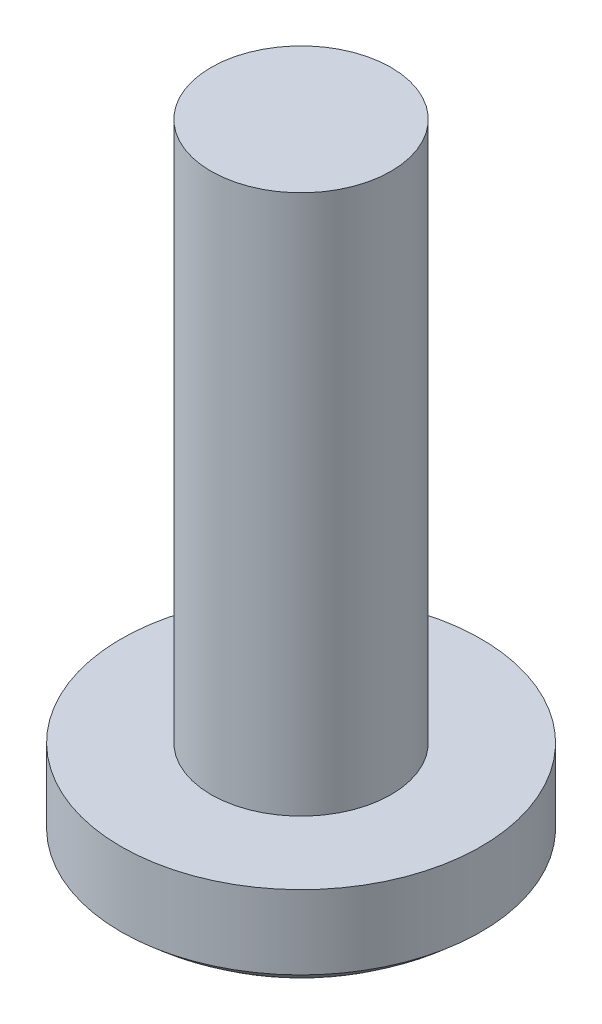
from build123d import *

# Parameters (mm, degrees)
SKETCH_1_R          = 2
EXTRUDE_1_DEPTH     = 1.6
SKETCH_2_R          = 1
EXTRUDE_2_DEPTH     = 6
CUT_EXTRUDE_1_DEPTH = 6


with BuildPart() as part:
    # 草图1 → 凸台-拉伸1 (new body)
    with BuildSketch(Plane(origin=(0, 0, 0), x_dir=(1, 0, 0), z_dir=(0, 1, 0))):
        Circle(SKETCH_1_R)
    extrude(amount=EXTRUDE_1_DEPTH)

    # 草图2 → 凸台-拉伸2 (add)
    with BuildSketch(Plane(origin=(0, 1.6, 0), x_dir=(1, 0, 0), z_dir=(0, 1, 0))):
        Circle(SKETCH_2_R)
    extrude(amount=EXTRUDE_2_DEPTH)

    # 草图3 one side → 切除-旋转3 (revolve, cut)
    with BuildSketch(Plane(origin=(0, 0, 0), x_dir=(0, 0, -1), z_dir=(1, 0, 0))):
        with BuildLine():
            ThreePointArc((2, 0.779106216), (1.073196918, 0.201653394), (0, 0))
            Line((0, 0), (0, -0.936416285))
            Line((0, -0.936416285), (3.543500435, -0.936416285))
            Line((3.543500435, -0.936416285), (2, 0.779106216))
        make_face()
    revolve(axis=Axis((0, 1.035939113, 0), (0, -1, 0)), mode=Mode.SUBTRACT)

    # 草图4 → 切除-拉伸1 (cut)
    with BuildSketch(Plane(origin=(0, -5, 0), x_dir=(1, 0, 0), z_dir=(0, 1, 0))):
        Polygon((-1, -0.2), (-0.2, -0.2), (-0.2, -1), (0.2, -1), (0.2, -0.2), (1, -0.2), (1, 0.2), (0.2, 0.2), (0.2, 1), (-0.2, 1), (-0.2, 0.2), (-1, 0.2), align=None)
    extrude(amount=CUT_EXTRUDE_1_DEPTH, mode=Mode.SUBTRACT)


solid = part.part
